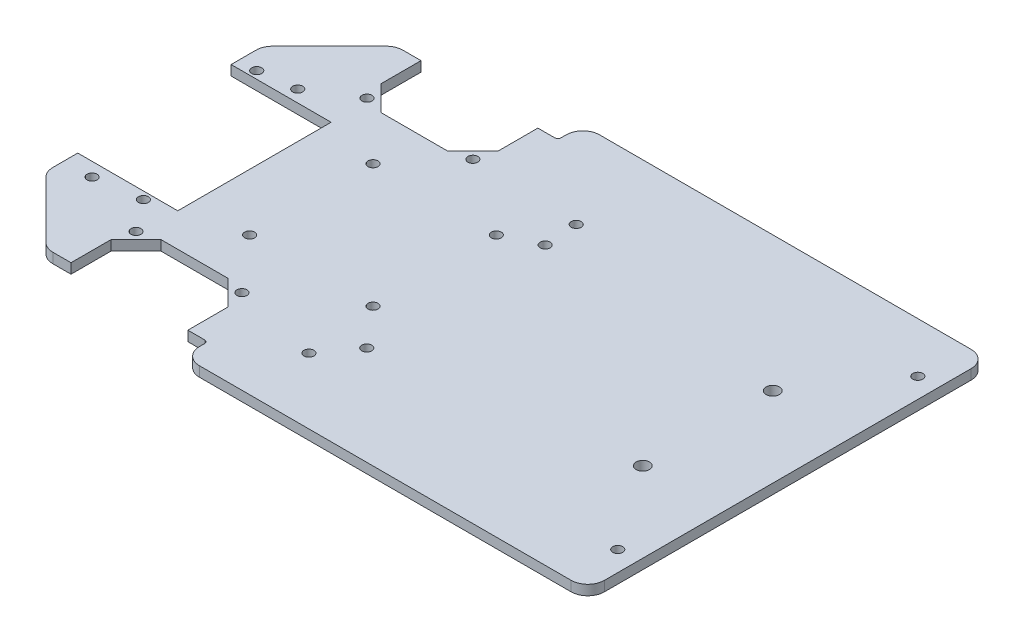
from build123d import *

# Parameters (mm, degrees)
BOSS_EXTRUDE1_DEPTH = 3
SKETCH4_W           = 30
SKETCH4_H           = 46
CUT_EXTRUDE1_DEPTH  = 3
FILLET1_R           = 5
FILLET2_R           = 1
SKETCH5_R           = 1.5
SKETCH5_R_2         = 2
CUT_EXTRUDE2_DEPTH  = 3


with BuildPart() as part:
    # Sketch1 → Boss-Extrude1 (new body)
    with BuildSketch(Plane(origin=(0, 0, 0), x_dir=(1, 0, 0), z_dir=(0, 1, 0))):
        Polygon((0, -32.526631134), (27.473368866, -60), (190, -60), (190, 60), (27.473368866, 60), (0, 32.526631134), (0, 23), (0, -23), align=None)
    extrude(amount=BOSS_EXTRUDE1_DEPTH)

    # Sketch4 → Cut-Extrude1 (cut)
    with BuildSketch(Plane(origin=(0, 0, 0), x_dir=(1, 0, 0), z_dir=(0, 1, 0))):
        Polygon((68.526631134, -60), (68.526631134, -52.5), (62.526631134, -52.5), (62.526631134, -40.526631134), (55, -33), (35, -33), (27.473368866, -40.526631134), (27.473368866, -52.5), (19.973368866, -52.5), (27.473368866, -60), align=None)
        Polygon((27.473368866, 60), (68.526631134, 60), (68.526631134, 52.5), (62.526631134, 52.5), (62.526631134, 40.526631134), (55, 33), (35, 33), (27.473368866, 40.526631134), (27.473368866, 52.5), (19.973368866, 52.5), align=None)
        with Locations((15, 0)):
            Rectangle(SKETCH4_W, SKETCH4_H)
    extrude(amount=CUT_EXTRUDE1_DEPTH, mode=Mode.SUBTRACT)

    # Fillet1
    fillet1_edges = [part.edges().sort_by_distance(p)[0] for p in [
        (190, 1.5, -60),
        (190, 1.5, 60),
        (0, 1.5, 32.526631134),
        (0, 1.5, -32.526631134),
        (68.526631134, 1.5, 60),
        (19.973368866, 1.5, 52.5),
        (19.973368866, 1.5, -52.5),
        (68.526631134, 1.5, -60),
    ]]
    fillet(fillet1_edges, radius=FILLET1_R)

    # Fillet2
    fillet2_edges = [part.edges().sort_by_distance(p)[0] for p in [
        (68.526631134, 1.5, 52.5),
        (68.526631134, 1.5, -52.5),
    ]]
    fillet(fillet2_edges, radius=FILLET2_R)

    # Sketch5 → Cut-Extrude2 (cut)
    with BuildSketch(Plane(origin=(0, 0, 0), x_dir=(1, 0, 0), z_dir=(0, 1, 0))):
        with Locations((47.062554885, -18.5)):
            Circle(SKETCH5_R)
        with Locations((84.062554885, -18.5)):
            Circle(SKETCH5_R)
        with Locations((84.062554885, 18.5)):
            Circle(SKETCH5_R)
        with Locations((47.062554885, 18.5)):
            Circle(SKETCH5_R)
        with Locations((94, 23.219474586)):
            Circle(SKETCH5_R)
        with Locations((93.305417602, 33.219474586)):
            Circle(SKETCH5_R)
        with Locations((29.11536409, 34.641995223)):
            Circle(SKETCH5_R)
        with Locations((60.88463591, 34.641995223)):
            Circle(SKETCH5_R)
        with Locations((8.367356219, -27.085410895)):
            Circle(SKETCH5_R)
        with Locations((16.379446424, 26.606355181)):
            Circle(SKETCH5_R)
        with Locations((94, -30.308001182)):
            Circle(SKETCH5_R)
        with Locations((86.659783805, -40.308001182)):
            Circle(SKETCH5_R)
        with Locations((184, -45)):
            Circle(SKETCH5_R)
        with Locations((184, 45)):
            Circle(SKETCH5_R)
        with Locations((166, -19.5)):
            Circle(SKETCH5_R_2)
        with Locations((166, 19.5)):
            Circle(SKETCH5_R_2)
        with Locations((29.11536409, -34.641995223)):
            Circle(SKETCH5_R)
        with Locations((60.88463591, -34.641995223)):
            Circle(SKETCH5_R)
        with Locations((21.933678109, -25.25)):
            Circle(SKETCH5_R)
        with Locations((5.439723212, 25.25)):
            Circle(SKETCH5_R)
    extrude(amount=CUT_EXTRUDE2_DEPTH, mode=Mode.SUBTRACT)


solid = part.part
